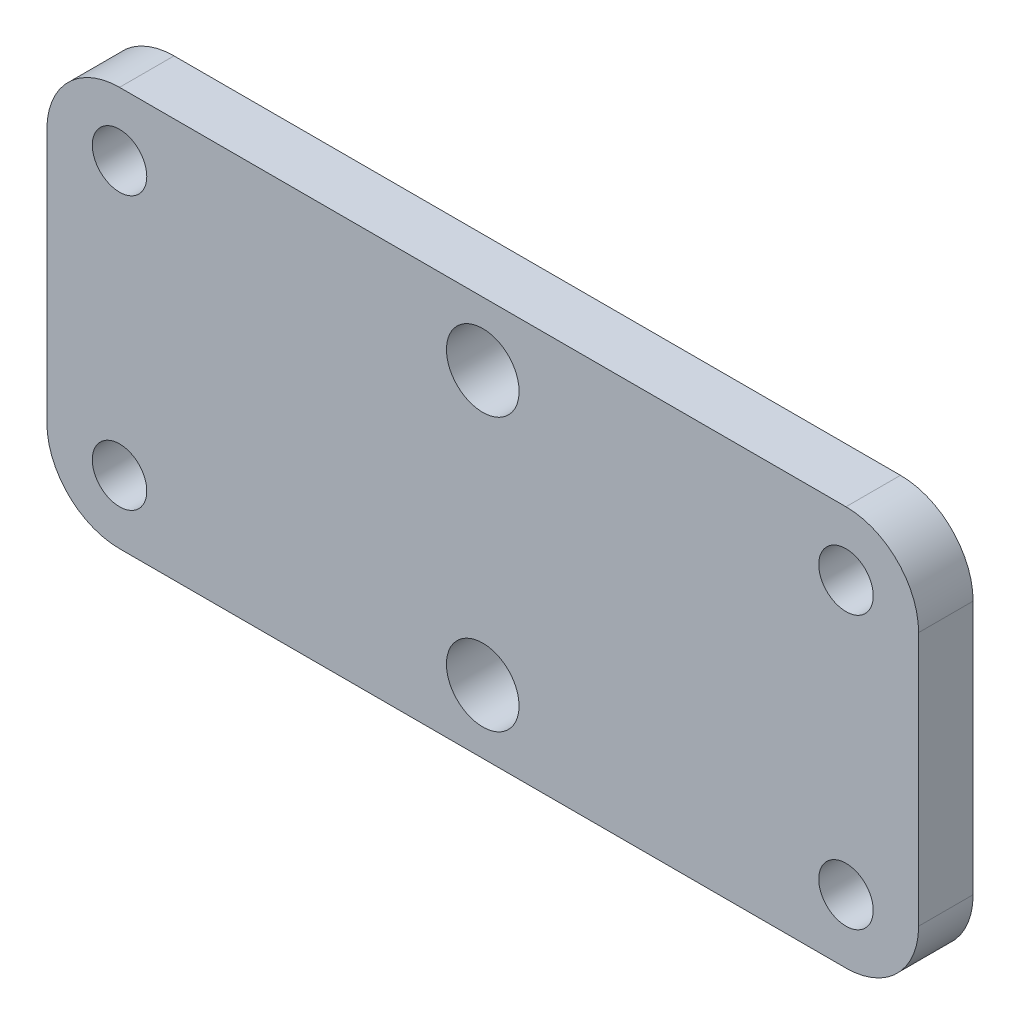
from build123d import *

# Parameters (mm, degrees)
ESQUISSE1_W        = 48
ESQUISSE1_H        = 22
ESQUISSE1_R        = 2
ESQUISSE1_R_2      = 1.5
BOSS_EXTRU_1_DEPTH = 3
CONG_1_R           = 4


with BuildPart() as part:
    # Esquisse1 → Boss.-Extru.1 (new body)
    with BuildSketch(Plane.XY):
        with Locations((24, -11)):
            Rectangle(ESQUISSE1_W, ESQUISSE1_H)
        with Locations((24, -3.5)):
            Circle(ESQUISSE1_R, mode=Mode.SUBTRACT)
        with Locations((24, -18.5)):
            Circle(ESQUISSE1_R, mode=Mode.SUBTRACT)
        with Locations((4, -3.5)):
            Circle(ESQUISSE1_R_2, mode=Mode.SUBTRACT)
        with Locations((44, -3.5)):
            Circle(ESQUISSE1_R_2, mode=Mode.SUBTRACT)
        with Locations((44, -18.5)):
            Circle(ESQUISSE1_R_2, mode=Mode.SUBTRACT)
        with Locations((4, -18.5)):
            Circle(ESQUISSE1_R_2, mode=Mode.SUBTRACT)
    extrude(amount=BOSS_EXTRU_1_DEPTH)

    # Congé1
    cong_1_edges = [part.edges().sort_by_distance(p)[0] for p in [
        (0, 0, 1.5),
        (48, 0, 1.5),
        (48, -22, 1.5),
        (0, -22, 1.5),
    ]]
    fillet(cong_1_edges, radius=CONG_1_R)


solid = part.part
